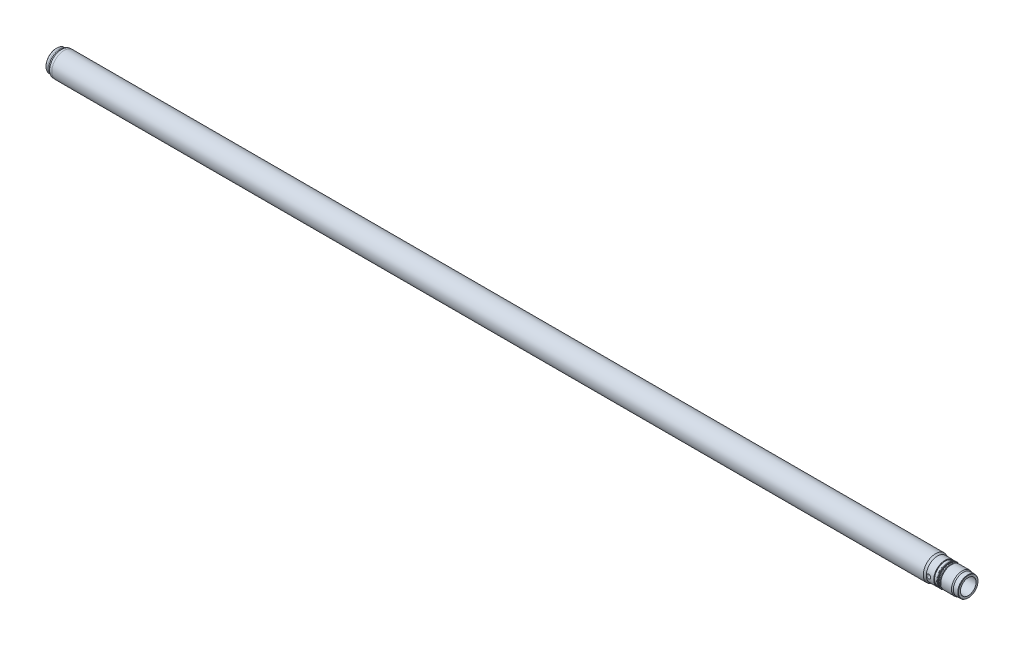
from build123d import *

# Parameters (mm, degrees)
SKETCH2_R                  = 4.5
F_9_GENNEMG_ENDE_HUL_DEPTH = 50


with BuildPart() as part:
    # Sketch1 → Base-Revolve (revolve)
    with BuildSketch(Plane.XY):
        with BuildLine():
            Line((0, 21), (0, 23.5))
            Line((0, 23.5), (0.5, 24))
            Line((0.5, 24), (5, 24))
            Line((5, 24), (5, 24.75))
            Line((5, 24.75), (7.5, 24.75))
            Line((7.5, 24.75), (11.830127019, 27.25))
            Line((11.830127019, 27.25), (17, 27.25))
            Line((17, 27.25), (17, 27.5))
            Line((17, 27.5), (1971.669872981, 27.5))
            Line((1971.669872981, 27.5), (1976, 25))
            Line((1976, 25), (1992.5, 25))
            ThreePointArc((1992.5, 25), (1992.853553391, 24.853553391), (1993, 24.5))
            Line((1993, 24.5), (1993, 23.5))
            Line((1993, 23.5), (1999, 23.5))
            Line((1999, 23.5), (1999, 24.5))
            ThreePointArc((1999, 24.5), (1999.146446609, 24.853553391), (1999.5, 25))
            Line((1999.5, 25), (2001, 25))
            Line((2001, 25), (2002, 24.422649731))
            Line((2002, 24.422649731), (2002, 23.75))
            ThreePointArc((2002, 23.75), (2002.292893219, 23.042893219), (2003, 22.75))
            Line((2003, 22.75), (2005, 22.75))
            Line((2005, 22.75), (2007.453263132, 24))
            Line((2007.453263132, 24), (2031.401923789, 24))
            Line((2031.401923789, 24), (2034, 22.5))
            Line((2034, 22.5), (2044, 22.5))
            Line((2044, 22.5), (2045, 21.922649731))
            Line((2045, 21.922649731), (2045, 17.5))
            Line((2045, 17.5), (6.062177826, 17.5))
            Line((6.062177826, 17.5), (0, 21))
        make_face()
    revolve(axis=Axis((0, 0, 0), (1, 0, 0)))

    # Sketch2 → ø9 gennemgående hul (cut, symmetric)
    with BuildSketch(Plane.XY):
        with Locations((1981, 0)):
            Circle(SKETCH2_R)
    extrude(amount=F_9_GENNEMG_ENDE_HUL_DEPTH, both=True, mode=Mode.SUBTRACT)


solid = part.part
